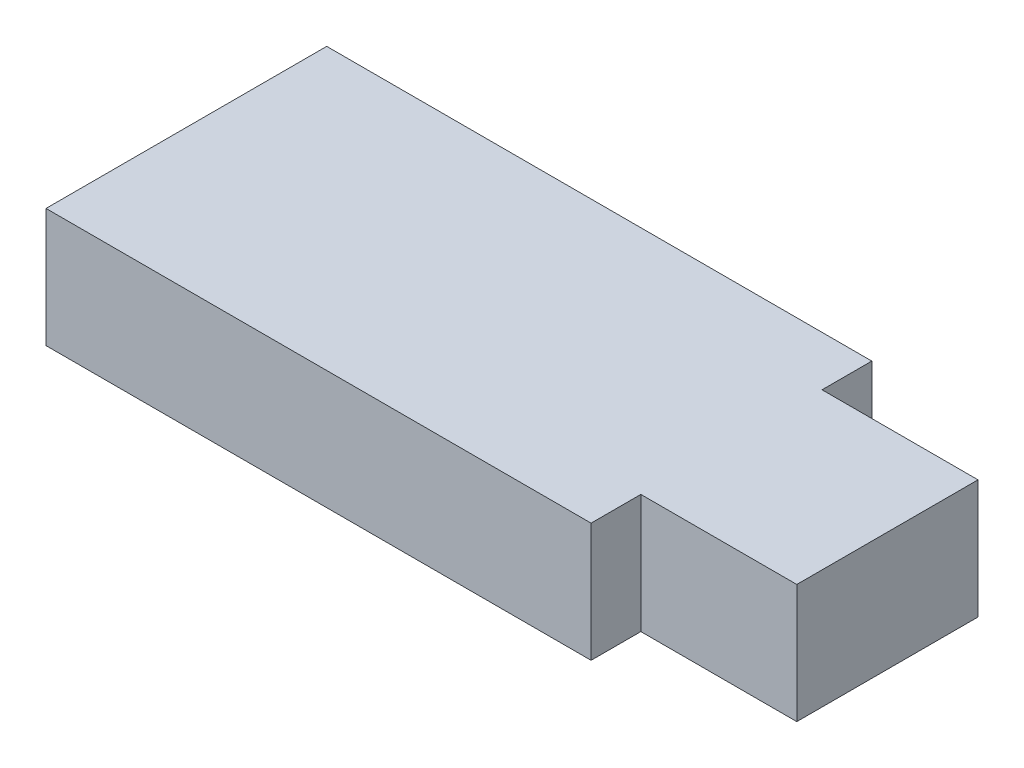
from build123d import *

# Parameters (mm, degrees)
BOSS_EXTRUDE1_DEPTH = 8


with BuildPart() as part:
    # Sketch1 → Boss-Extrude1 (new body)
    with BuildSketch(Plane(origin=(0, 0, 0), x_dir=(1, 0, 0), z_dir=(0, 1, 0))):
        Polygon((0, 0), (0, 18.9), (36.7, 18.9), (36.7, 15.55), (47.2, 15.55), (47.2, 3.35), (36.7, 3.35), (36.7, 0), align=None)
    extrude(amount=BOSS_EXTRUDE1_DEPTH)


solid = part.part
